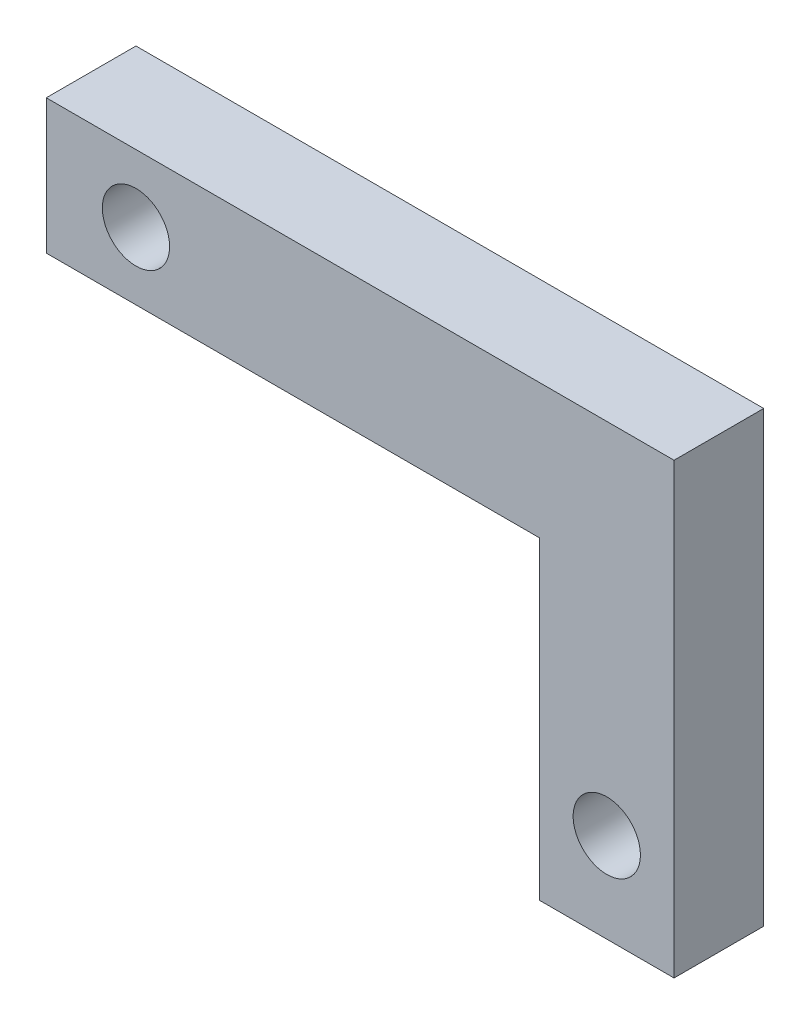
from build123d import *

# Parameters (mm, degrees)
SKETCH1_W           = 177.8
SKETCH1_H           = 38.1
SKETCH1_W_2         = 38.1
SKETCH1_H_2         = 88.9
BOSS_EXTRUDE1_DEPTH = 25.4
SKETCH2_R           = 9.525
CUT_EXTRUDE1_DEPTH  = 26.4
SKETCH3_R           = 9.525
CUT_EXTRUDE2_DEPTH  = 26.4


with BuildPart() as part:
    # Sketch1 → Boss-Extrude1 (new body)
    with BuildSketch(Plane.XY):
        with Locations((88.9, 19.05)):
            Rectangle(SKETCH1_W, SKETCH1_H)
        with Locations((158.75, -44.45)):
            Rectangle(SKETCH1_W_2, SKETCH1_H_2)
    extrude(amount=BOSS_EXTRUDE1_DEPTH)

    # Sketch2 → Cut-Extrude1 (cut, through all)
    with BuildSketch(Plane.XY.offset(25.4)):
        with Locations((25.4, 19.05)):
            Circle(SKETCH2_R)
    extrude(amount=-CUT_EXTRUDE1_DEPTH, mode=Mode.SUBTRACT)

    # Sketch3 → Cut-Extrude2 (cut, through all)
    with BuildSketch(Plane.XY.offset(25.4)):
        with Locations((158.75, -63.5)):
            Circle(SKETCH3_R)
    extrude(amount=-CUT_EXTRUDE2_DEPTH, mode=Mode.SUBTRACT)


solid = part.part
